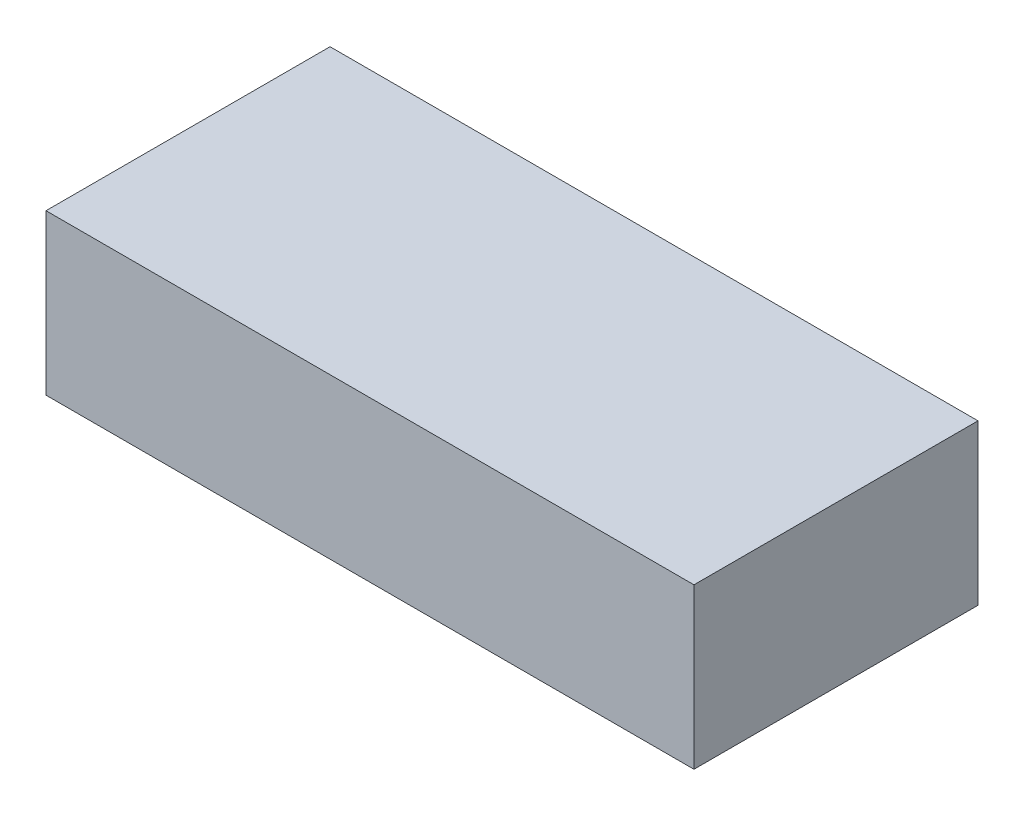
from build123d import *

# Parameters (mm, degrees)
SKETCH1_W           = 73
SKETCH1_H           = 32
BOSS_EXTRUDE1_DEPTH = 18


with BuildPart() as part:
    # Sketch1 → Boss-Extrude1 (new body)
    with BuildSketch(Plane(origin=(0, 0, 0), x_dir=(1, 0, 0), z_dir=(0, 1, 0))):
        Rectangle(SKETCH1_W, SKETCH1_H)
    extrude(amount=BOSS_EXTRUDE1_DEPTH)


solid = part.part
